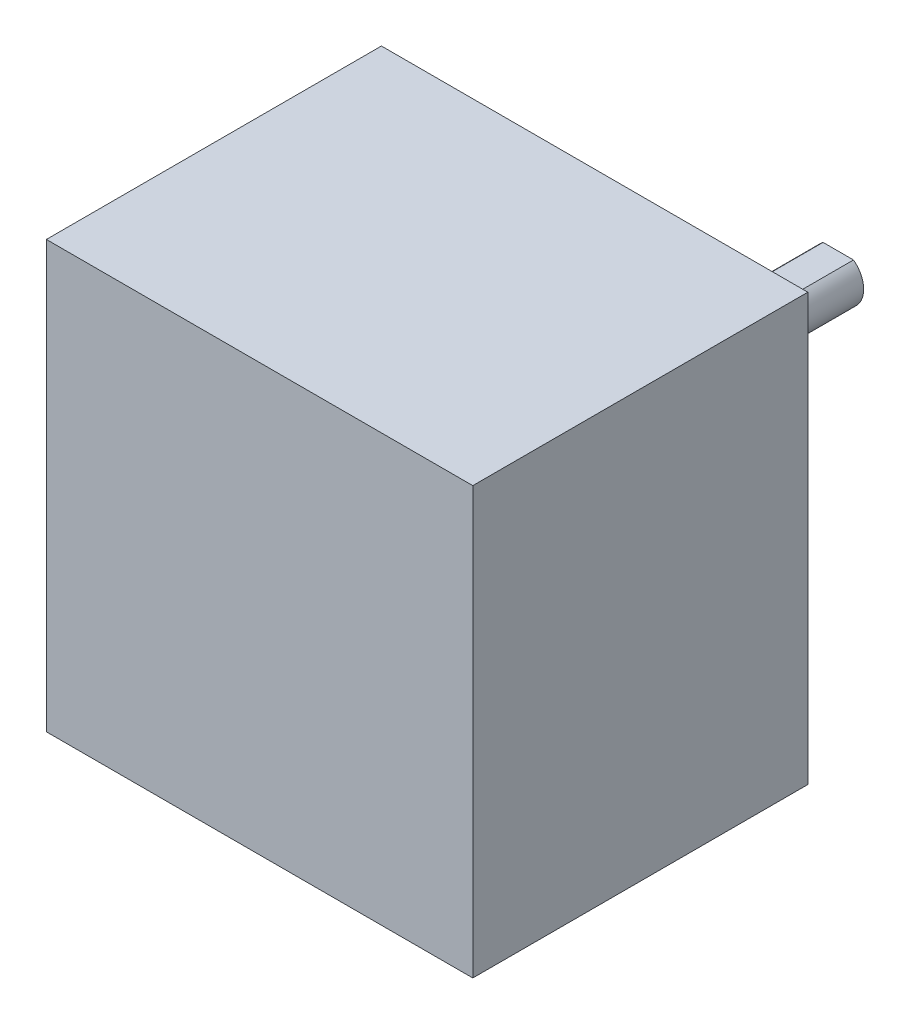
from build123d import *

# Parameters (mm, degrees)
SKETCH1_W           = 42
SKETCH1_H           = 42
BOSS_EXTRUDE1_DEPTH = 33
SKETCH2_R           = 11.793537184
BOSS_EXTRUDE2_DEPTH = 2
SKETCH3_R           = 2.5
BOSS_EXTRUDE3_DEPTH = 22
CUT_EXTRUDE1_DEPTH  = 20


with BuildPart() as part:
    # Sketch1 → Boss-Extrude1 (new body)
    with BuildSketch(Plane.XY):
        Rectangle(SKETCH1_W, SKETCH1_H)
    extrude(amount=BOSS_EXTRUDE1_DEPTH)

    # Sketch2 → Boss-Extrude2 (add)
    with BuildSketch(Plane(origin=(0, 0, 0), x_dir=(-1, 0, 0), z_dir=(0, 0, -1))):
        Circle(SKETCH2_R)
    extrude(amount=BOSS_EXTRUDE2_DEPTH)

    # Sketch3 → Boss-Extrude3 (add)
    with BuildSketch(Plane(origin=(0, 0, -2), x_dir=(-1, 0, 0), z_dir=(0, 0, -1))):
        Circle(SKETCH3_R)
    extrude(amount=BOSS_EXTRUDE3_DEPTH)

    # Sketch4 → Cut-Extrude1 (cut)
    with BuildSketch(Plane(origin=(0, 0, -24), x_dir=(-1, 0, 0), z_dir=(0, 0, -1))):
        with BuildLine():
            Line((1.5, 2), (-1.5, 2))
            ThreePointArc((-1.5, 2), (0, 2.5), (1.5, 2))
        make_face()
    extrude(amount=-CUT_EXTRUDE1_DEPTH, mode=Mode.SUBTRACT)


solid = part.part
